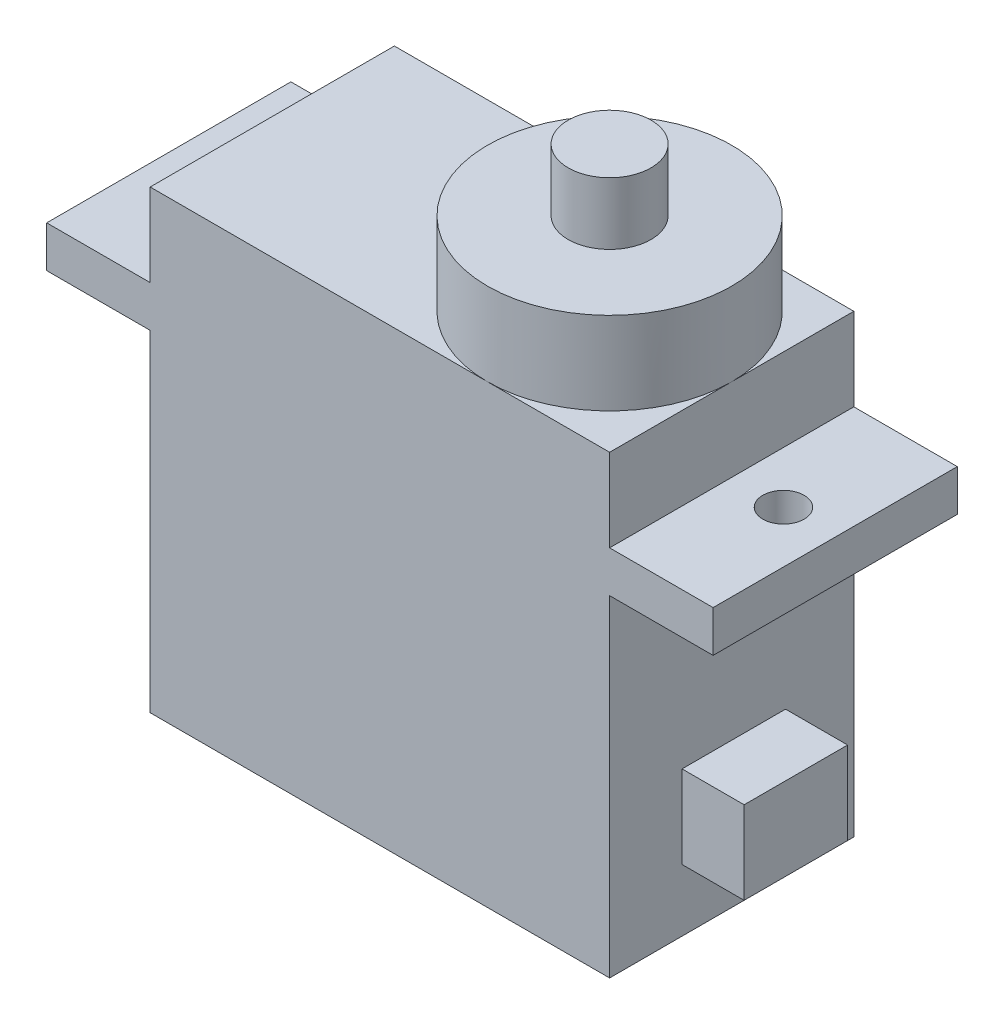
from build123d import *

# Parameters (mm, degrees)
BOSS_EXTRU_1_DEPTH      = 11.8
ESQUISSE2_R             = 1
ENL_V_MAT_EXTRU_1_DEPTH = 11.8
ESQUISSE3_R             = 5.9
BOSS_EXTRU_2_DEPTH      = 4
ESQUISSE4_R             = 2
BOSS_EXTRU_3_DEPTH      = 3
ESQUISSE5_W             = 5
ESQUISSE5_H             = 4
BOSS_EXTRU_4_DEPTH      = 3


with BuildPart() as part:
    # Esquisse1 → Boss.-Extru.1 (new body)
    with BuildSketch(Plane.XY):
        Polygon((-45.196459949, 18), (-40.196459949, 18), (-40.196459949, 22), (-17.996459949, 22), (-17.996459949, 18), (-12.996459949, 18), (-12.996459949, 16), (-17.996459949, 16), (-17.996459949, 0), (-40.196459949, 0), (-40.196459949, 16), (-45.196459949, 16), align=None)
    extrude(amount=BOSS_EXTRU_1_DEPTH)

    # Esquisse2 → Enlèv. mat.-Extru.1 (cut)
    with BuildSketch(Plane(origin=(0, 18, 0), x_dir=(1, 0, 0), z_dir=(0, 1, 0))):
        with Locations((-42.696459949, -5.9)):
            Circle(ESQUISSE2_R)
        with Locations((-15.496459949, -5.9)):
            Circle(ESQUISSE2_R)
    extrude(amount=-ENL_V_MAT_EXTRU_1_DEPTH, mode=Mode.SUBTRACT)

    # Esquisse3 → Boss.-Extru.2 (add)
    with BuildSketch(Plane(origin=(0, 22, 0), x_dir=(1, 0, 0), z_dir=(0, 1, 0))):
        with Locations((-23.896459949, -5.9)):
            Circle(ESQUISSE3_R)
    extrude(amount=BOSS_EXTRU_2_DEPTH)

    # Esquisse4 → Boss.-Extru.3 (add)
    with BuildSketch(Plane(origin=(0, 26, 0), x_dir=(1, 0, 0), z_dir=(0, 1, 0))):
        with Locations((-23.896459949, -5.9)):
            Circle(ESQUISSE4_R)
    extrude(amount=BOSS_EXTRU_3_DEPTH)

    # Esquisse5 → Boss.-Extru.4 (add)
    with BuildSketch(Plane(origin=(-17.996459949, 0, 0), x_dir=(0, 0, -1), z_dir=(1, 0, 0))):
        with Locations((-5.8, 5)):
            Rectangle(ESQUISSE5_W, ESQUISSE5_H)
    extrude(amount=BOSS_EXTRU_4_DEPTH)


solid = part.part
